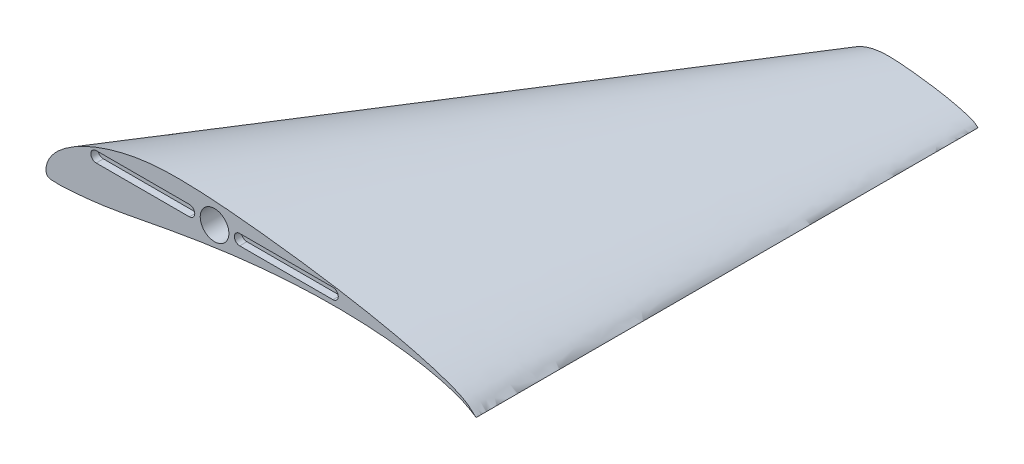
from build123d import *

# Parameters (mm, degrees)
SKETCH4_R          = 2
CUT_EXTRUDE1_DEPTH = 10
CUT_EXTRUDE2_DEPTH = 1


with BuildPart() as part:
    # Sketch3 → Loft1 section 0
    with BuildSketch(Plane.XY.offset(70)):
        with BuildLine():
            add(Edge.make_bspline(
                [(60, 0), (60.000107759, 0.00045823), (59.940935145, 0.044545857), (59.890891538, 0.093647308), (59.779774511, 0.196205337), (59.648682422, 0.305307561), (59.469359582, 0.415294301), (59.246370858, 0.521886024), (58.977168165, 0.633116991), (58.662177205, 0.747496515), (58.302798195, 0.863953961), (57.901335106, 0.982592376), (57.458471962, 1.097979924), (56.979558848, 1.219684363), (56.464360521, 1.335758178), (55.917664884, 1.451163432), (55.342255391, 1.563645721), (54.741619221, 1.672310848), (54.119503088, 1.776862794), (53.479502393, 1.875995081), (52.825753205, 1.969890082), (52.162446062, 2.057806833), (51.494385085, 2.13946315), (50.826910973, 2.215437436), (50.165549402, 2.283812601), (49.515688388, 2.343308945), (48.88189852, 2.390577682), (48.267800241, 2.423092507), (47.676809978, 2.437133923), (47.111955291, 2.435639306), (46.574289852, 2.407982369), (46.063605386, 2.351936832), (45.577823009, 2.272687612), (45.116825477, 2.170020947), (44.681086398, 2.04962996), (44.272449438, 1.913646961), (43.892652493, 1.765251918), (43.544055665, 1.605239875), (43.227776887, 1.436859538), (42.94553682, 1.262025717), (42.699105421, 1.083107561), (42.488584367, 0.903897458), (42.317026583, 0.722439194), (42.185248322, 0.540304202), (42.08790704, 0.363111111), (42.025521579, 0.194874666), (41.995794905, 0.039592478), (42.001532957, -0.091739447), (42.035344873, -0.212191985), (42.16102918, -0.271985507), (42.33001338, -0.28037435), (42.561183137, -0.288504849), (42.85189542, -0.275968725), (43.198864607, -0.252931149), (43.598229294, -0.216029949), (44.045902873, -0.166101037), (44.539702369, -0.102073031), (45.07938647, -0.012584366), (45.667582852, 0.09963297), (46.307232102, 0.221761241), (46.995207664, 0.350711186), (47.72718833, 0.481130505), (48.497798407, 0.608124713), (49.301059449, 0.727453141), (50.130048988, 0.834738394), (50.977312155, 0.926856584), (51.834845451, 0.99967222), (52.694043317, 1.051289527), (53.545929342, 1.07966642), (54.381262057, 1.083250625), (55.190722018, 1.061798612), (55.965040428, 1.015812577), (56.694906217, 0.945885863), (57.371629898, 0.8547026), (57.986400744, 0.744908581), (58.532010839, 0.620180946), (58.99840484, 0.486716819), (59.380100231, 0.344272382), (59.652430067, 0.213917485), (59.853211585, 0.093386968), (59.93034321, 0.046743647), (59.99989005, -0.000467545), (60, 0)],
                knots=[0, 0, 0, 0, 0.000979678, 0.003648865, 0.007483504, 0.012095286, 0.017525603, 0.024051797, 0.031783073, 0.040677857, 0.050710337, 0.061833274, 0.073978206, 0.087117514, 0.1011444, 0.115989999, 0.131569795, 0.147787764, 0.164550314, 0.181757305, 0.199311377, 0.217094507, 0.234989676, 0.252856344, 0.270540067, 0.287886265, 0.304772936, 0.321100929, 0.336805584, 0.351799565, 0.366030606, 0.379615227, 0.392652524, 0.405169929, 0.417171498, 0.428603104, 0.439418554, 0.449596189, 0.459101689, 0.467907493, 0.475987922, 0.483308596, 0.48987414, 0.495802886, 0.501149052, 0.505902717, 0.510046415, 0.51357896, 0.516446578, 0.519349706, 0.523823011, 0.529973455, 0.537715321, 0.546967517, 0.557637048, 0.56962017, 0.582803823, 0.59724667, 0.613134757, 0.630443334, 0.64905587, 0.668822018, 0.68959474, 0.711189442, 0.733426497, 0.756093941, 0.778988394, 0.80188954, 0.824566471, 0.846792174, 0.868338195, 0.888978083, 0.908491945, 0.926658715, 0.943286152, 0.95816918, 0.971135801, 0.98195561, 0.990251784, 0.995852562, 0.999000405, 1, 1, 1, 1], degree=3))
        make_face()
    # Sketch2 → Loft1 section 1
    with BuildSketch(Plane.XY):
        with BuildLine():
            add(Edge.make_bspline(
                [(60, 0), (60.000359197, 0.001527432), (59.80311715, 0.148486191), (59.636305128, 0.312157693), (59.265915035, 0.654017791), (58.828941408, 1.01769187), (58.231198607, 1.384314338), (57.487902859, 1.739620081), (56.590560551, 2.110389969), (55.540590684, 2.491655052), (54.342660651, 2.879846537), (53.004450354, 3.275307919), (51.528239873, 3.659933081), (49.931862826, 4.065614543), (48.21453507, 4.45252726), (46.392216281, 4.837211439), (44.474184637, 5.212152404), (42.47206407, 5.574369492), (40.398343628, 5.92287598), (38.265007978, 6.253316937), (36.085844017, 6.566300275), (33.874820207, 6.859356111), (31.647950283, 7.131543832), (29.423036576, 7.384791452), (27.218498007, 7.612708672), (25.052294626, 7.811029816), (22.939661735, 7.968592274), (20.892667469, 8.076975023), (18.922699926, 8.123779744), (17.039850969, 8.118797688), (15.247632842, 8.026607898), (13.545351286, 7.839789441), (11.926076695, 7.575625373), (10.389418256, 7.233403155), (8.93695466, 6.832099867), (7.574831461, 6.378823205), (6.308841643, 5.884173059), (5.146852216, 5.350799583), (4.092589623, 4.789531794), (3.151789401, 4.20675239), (2.330351404, 3.610358538), (1.628614556, 3.012991527), (1.056755276, 2.408130647), (0.617494407, 1.801014007), (0.293023466, 1.210370369), (0.085071932, 0.649582219), (-0.014016985, 0.131974926), (0.005109858, -0.305798158), (0.117816245, -0.707306616), (0.536763933, -0.906618356), (1.100044602, -0.934581165), (1.870610456, -0.96168283), (2.8396514, -0.91989575), (3.996215358, -0.843103831), (5.32743098, -0.720099828), (6.819676242, -0.553670124), (8.465674563, -0.340243438), (10.264621567, -0.041947886), (12.225276175, 0.332109901), (14.357440339, 0.739204138), (16.650692214, 1.169037288), (19.090627767, 1.60376835), (21.659328024, 2.027082377), (24.336864829, 2.424843805), (27.100163295, 2.782461315), (29.924373851, 3.089521947), (32.78281817, 3.332240734), (35.646811058, 3.504298425), (38.486431141, 3.598888068), (41.270873525, 3.610835418), (43.969073393, 3.539328707), (46.550134759, 3.386041923), (48.983020725, 3.152952876), (51.238766327, 2.849008665), (53.28800248, 2.483028604), (55.106702797, 2.06726982), (56.661349467, 1.622389398), (57.933667436, 1.147574605), (58.841433556, 0.713058282), (59.510705283, 0.311289894), (59.767810701, 0.155812155), (59.999633501, -0.001558484), (60, 0)],
                knots=[0, 0, 0, 0, 0.000979678, 0.003648865, 0.007483504, 0.012095286, 0.017525603, 0.024051797, 0.031783073, 0.040677857, 0.050710337, 0.061833274, 0.073978206, 0.087117514, 0.1011444, 0.115989999, 0.131569795, 0.147787764, 0.164550314, 0.181757305, 0.199311377, 0.217094507, 0.234989676, 0.252856344, 0.270540067, 0.287886265, 0.304772936, 0.321100929, 0.336805584, 0.351799565, 0.366030606, 0.379615227, 0.392652524, 0.405169929, 0.417171498, 0.428603104, 0.439418554, 0.449596189, 0.459101689, 0.467907493, 0.475987922, 0.483308596, 0.48987414, 0.495802886, 0.501149052, 0.505902717, 0.510046415, 0.51357896, 0.516446578, 0.519349706, 0.523823011, 0.529973455, 0.537715321, 0.546967517, 0.557637048, 0.56962017, 0.582803823, 0.59724667, 0.613134757, 0.630443334, 0.64905587, 0.668822018, 0.68959474, 0.711189442, 0.733426497, 0.756093941, 0.778988394, 0.80188954, 0.824566471, 0.846792174, 0.868338195, 0.888978083, 0.908491945, 0.926658715, 0.943286152, 0.95816918, 0.971135801, 0.98195561, 0.990251784, 0.995852562, 0.999000405, 1, 1, 1, 1], degree=3))
        make_face()
    loft()

    # Sketch4 → Cut-Extrude1 (cut)
    with BuildSketch(Plane(origin=(0, 0, 0), x_dir=(-1, 0, 0), z_dir=(0, 0, -1))):
        with Locations((-23.51, 5)):
            Circle(SKETCH4_R)
    extrude(amount=-CUT_EXTRUDE1_DEPTH, mode=Mode.SUBTRACT)

    # Sketch4_3 → Cut-Extrude2 (cut)
    with BuildSketch(Plane(origin=(0, 0, 0), x_dir=(-1, 0, 0), z_dir=(0, 0, -1))):
        with BuildLine():
            Line((-40.02, 5.75), (-27.02, 5.75))
            ThreePointArc((-27.02, 5.75), (-26.27, 5), (-27.02, 4.25))
            Line((-27.02, 4.25), (-40.02, 4.25))
            ThreePointArc((-40.02, 4.25), (-40.77, 5), (-40.02, 5.75))
        make_face()
        with BuildLine():
            Line((-7, 5.75), (-20, 5.75))
            ThreePointArc((-20, 5.75), (-20.75, 5), (-20, 4.25))
            Line((-20, 4.25), (-7, 4.25))
            ThreePointArc((-7, 4.25), (-6.25, 5), (-7, 5.75))
        make_face()
    extrude(amount=-CUT_EXTRUDE2_DEPTH, mode=Mode.SUBTRACT)


with BuildPart() as body_2:
    # Mirror2: mirrored copy
    add(part.part.mirror(Plane(origin=(0.358648894, 1.312038357, 0), x_dir=(1, 0, 0), z_dir=(0, 0, -1))))


solid = body_2.part
